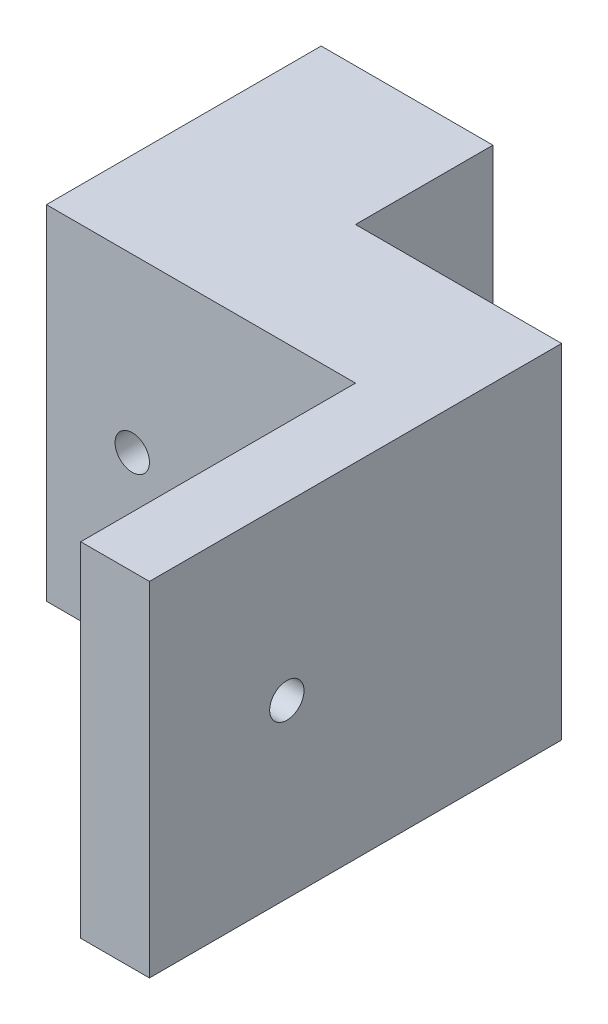
from build123d import *

# Parameters (mm, degrees)
CROQUIS1_W                                     = 25
CROQUIS1_H                                     = 50
SALIENTE_EXTRUIR1_DEPTH                        = 20
CROQUIS2_W                                     = 45
CROQUIS2_H                                     = 50
SALIENTE_EXTRUIR2_DEPTH                        = 20
CROQUIS5_W                                     = 20
CROQUIS5_H                                     = 50
CROQUIS5_W_2                                   = 40
SALIENTE_EXTRUIR3_DEPTH                        = 10
PERFORADOR_PARA_ROSCAR_PARA_MACHO_DE_ROS_D     = 5
PERFORADOR_PARA_ROSCAR_PARA_MACHO_DE_ROS_DEPTH = 11
PERFORADOR_PARA_ROSCAR_PARA_MACHO_DE_ROS_TIP   = 1.502151548
PERFORADOR_PARA_ROSCAR_PARA_MACHO_DE_2_D       = 5


with BuildPart() as part:
    # Croquis1 → Saliente-Extruir1 (new body)
    with BuildSketch(Plane.XY):
        with Locations((-28.587290739, 5.380089213)):
            Rectangle(CROQUIS1_W, CROQUIS1_H)
    extrude(amount=SALIENTE_EXTRUIR1_DEPTH)

    # Croquis2 → Saliente-Extruir2 (add)
    with BuildSketch(Plane.XY.offset(20)):
        with Locations((-18.587290739, 5.380089213)):
            Rectangle(CROQUIS2_W, CROQUIS2_H)
    extrude(amount=SALIENTE_EXTRUIR2_DEPTH)

    # Croquis5 → Saliente-Extruir3 (add)
    with BuildSketch(Plane(origin=(3.912709261, 0, 0), x_dir=(0, 0, -1), z_dir=(1, 0, 0))):
        with Locations((-30, 5.380089213)):
            Rectangle(CROQUIS5_W, CROQUIS5_H)
        with Locations((-60, 5.380089213)):
            Rectangle(CROQUIS5_W_2, CROQUIS5_H)
    extrude(amount=SALIENTE_EXTRUIR3_DEPTH)

    # Perforador para roscar para macho de ros
    with Locations(Plane(origin=(3.912709261, 5.380089213, 60), x_dir=(0, 0, -1), z_dir=(-1, 0, 0))):
        with Locations((0, 0)):
            Hole(PERFORADOR_PARA_ROSCAR_PARA_MACHO_DE_ROS_D / 2, depth=PERFORADOR_PARA_ROSCAR_PARA_MACHO_DE_ROS_DEPTH)
            with Locations((0, 0, -(PERFORADOR_PARA_ROSCAR_PARA_MACHO_DE_ROS_DEPTH + PERFORADOR_PARA_ROSCAR_PARA_MACHO_DE_ROS_TIP / 2))):  # 118° drill point
                Cone(0, PERFORADOR_PARA_ROSCAR_PARA_MACHO_DE_ROS_D / 2, PERFORADOR_PARA_ROSCAR_PARA_MACHO_DE_ROS_TIP, mode=Mode.SUBTRACT)

    # Perforador para roscar para macho de 2 (through all)
    with Locations(Plane(origin=(-28.587290739, 5.380089213, 0), x_dir=(-1, 0, 0), z_dir=(0, 0, -1))):
        with Locations((0, 0)):
            Hole(PERFORADOR_PARA_ROSCAR_PARA_MACHO_DE_2_D / 2)


solid = part.part
